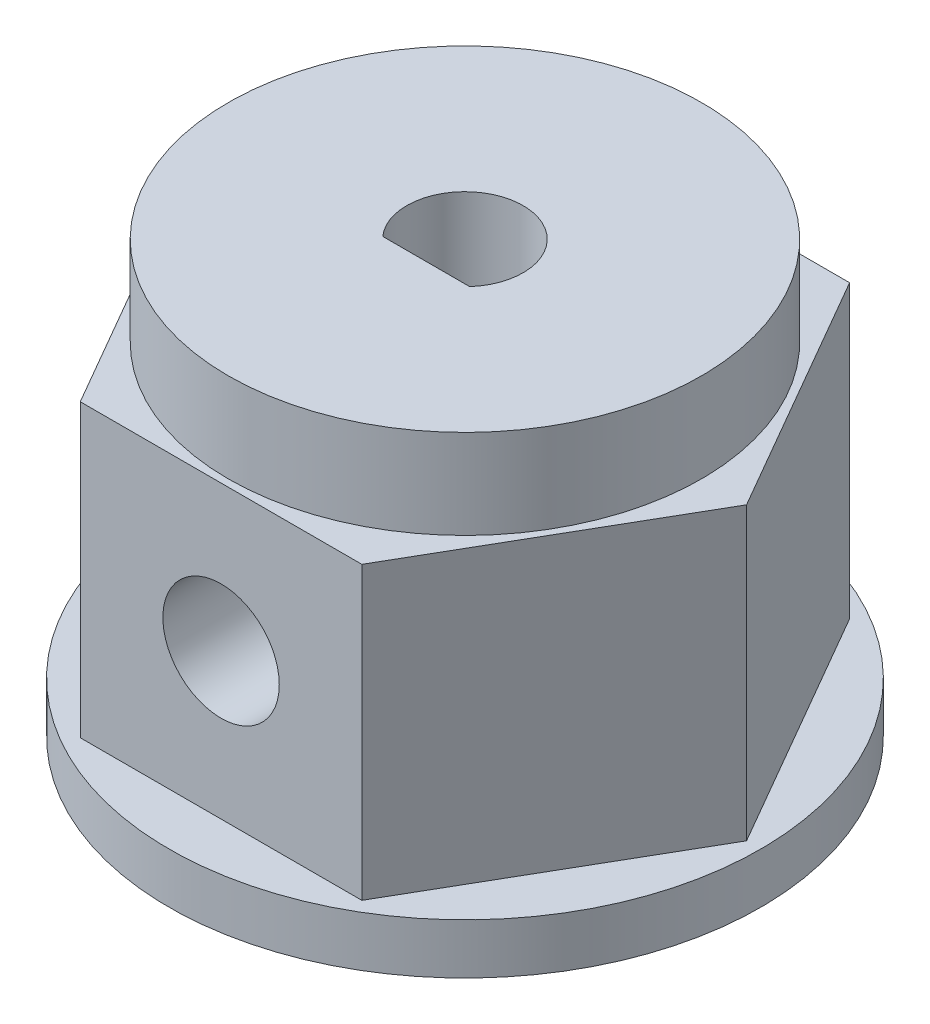
from build123d import *

# Parameters (mm, degrees)
BOSS_EXTRUDE1_DEPTH = 7.5
SKETCH2_R           = 6.1
BOSS_EXTRUDE2_DEPTH = 2.3
SKETCH3_R           = 7.625
BOSS_EXTRUDE3_DEPTH = 1.3
CUT_EXTRUDE1_DEPTH  = 12.1
CUT_EXTRUDE2_REACH  = 15.91
SKETCH5_R           = 1.5


with BuildPart() as part:
    # Sketch1 → Boss-Extrude1 (new body)
    with BuildSketch(Plane(origin=(0, 0, 0), x_dir=(1, 0, 0), z_dir=(0, 1, 0))):
        Polygon((7.257292884, 0), (3.628646442, 6.285), (-3.628646442, 6.285), (-7.257292884, 0), (-3.628646442, -6.285), (3.628646442, -6.285), align=None)
    extrude(amount=BOSS_EXTRUDE1_DEPTH)

    # Sketch2 → Boss-Extrude2 (add)
    with BuildSketch(Plane(origin=(0, 7.5, 0), x_dir=(1, 0, 0), z_dir=(0, 1, 0))):
        Circle(SKETCH2_R)
    extrude(amount=BOSS_EXTRUDE2_DEPTH)

    # Sketch3 → Boss-Extrude3 (add)
    with BuildSketch(Plane.XZ):
        Circle(SKETCH3_R)
    extrude(amount=BOSS_EXTRUDE3_DEPTH)

    # Sketch4 → Cut-Extrude1 (cut, through all)
    with BuildSketch(Plane(origin=(0, 9.8, 0), x_dir=(1, 0, 0), z_dir=(0, 1, 0))):
        with BuildLine():
            Line((-1.12, -0.997797575), (1.12, -0.997797575))
            ThreePointArc((1.12, -0.997797575), (0, 1.5), (-1.12, -0.997797575))
        make_face()
    extrude(amount=-CUT_EXTRUDE1_DEPTH, mode=Mode.SUBTRACT)

    # Sketch5 → Cut-Extrude2 (cut, up to next)
    with BuildSketch(Plane.XY.offset(6.285), mode=Mode.PRIVATE) as cut_extrude2_sk1:
        with Locations((0, 3.75)):
            Circle(SKETCH5_R)
    cut_extrude2_tool1 = extrude(cut_extrude2_sk1.sketch, amount=-CUT_EXTRUDE2_REACH, mode=Mode.PRIVATE) & part.part
    add(cut_extrude2_tool1.solids().sort_by_distance((0, 3.75, 6.285))[0], mode=Mode.SUBTRACT)


solid = part.part
